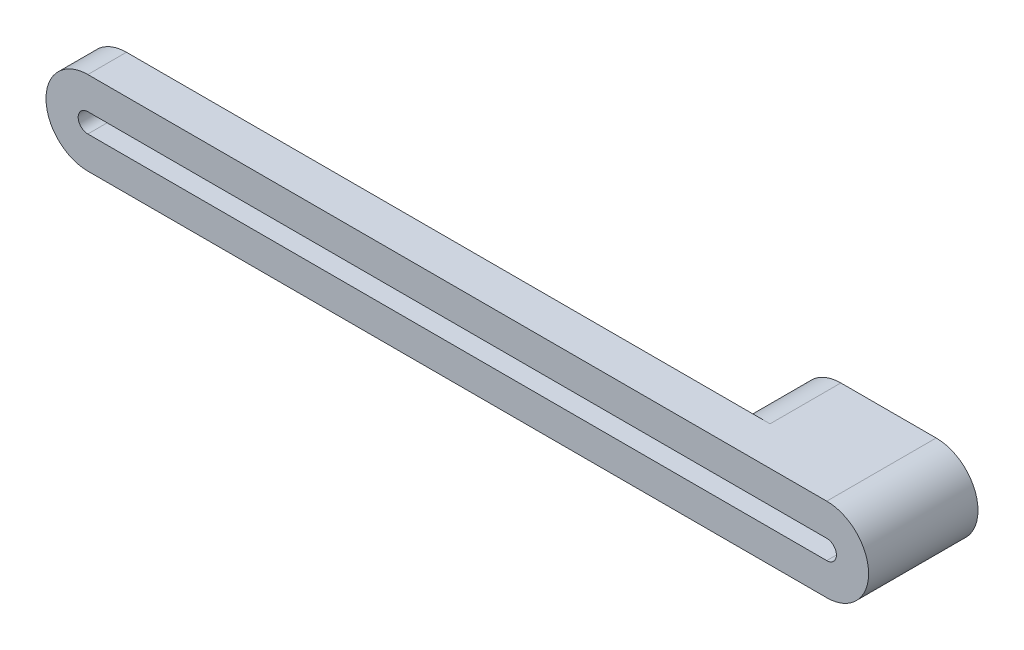
from build123d import *

# Parameters (mm, degrees)
BOSS_EXTRUDE1_DEPTH = 11
BOSS_EXTRUDE2_DEPTH = 6


with BuildPart() as part:
    # Sketch1 → Boss-Extrude1 (new body)
    with BuildSketch(Plane.XY):
        with BuildLine():
            Line((-68.865823893, 22.791817364), (-83.675684171, 22.791817364))
            ThreePointArc((-83.675684171, 22.791817364), (-90.175684171, 16.291817364), (-83.675684171, 9.791817364))
            Line((-83.675684171, 9.791817364), (-68.865823893, 9.791817364))
            ThreePointArc((-68.865823893, 9.791817364), (-62.365823893, 16.291817364), (-68.865823893, 22.791817364))
        make_face()
        with BuildLine():
            Line((-68.865823893, 17.791817364), (-83.675684171, 17.791817364))
            ThreePointArc((-83.675684171, 17.791817364), (-85.175684171, 16.291817364), (-83.675684171, 14.791817364))
            Line((-83.675684171, 14.791817364), (-68.865823893, 14.791817364))
            ThreePointArc((-68.865823893, 14.791817364), (-67.365823893, 16.291817364), (-68.865823893, 17.791817364))
        make_face(mode=Mode.SUBTRACT)
    extrude(amount=BOSS_EXTRUDE1_DEPTH)

    # Sketch2 → Boss-Extrude2 (add)
    with BuildSketch(Plane.XY.offset(11)):
        with BuildLine():
            Line((-183.675684171, 22.791817364), (-83.675684171, 22.791817364))
            Line((-83.675684171, 22.791817364), (-68.865823893, 22.791817364))
            ThreePointArc((-68.865823893, 22.791817364), (-62.365823893, 16.291817364), (-68.865823893, 9.791817364))
            Line((-68.865823893, 9.791817364), (-83.675684171, 9.791817364))
            Line((-83.675684171, 9.791817364), (-183.675684171, 9.791817364))
            ThreePointArc((-183.675684171, 9.791817364), (-190.175684171, 16.291817364), (-183.675684171, 22.791817364))
        make_face()
        with BuildLine():
            Line((-183.675684171, 17.791817364), (-83.675684171, 17.791817364))
            Line((-83.675684171, 17.791817364), (-68.865823893, 17.791817364))
            ThreePointArc((-68.865823893, 17.791817364), (-67.365823893, 16.291817364), (-68.865823893, 14.791817364))
            Line((-68.865823893, 14.791817364), (-83.675684171, 14.791817364))
            Line((-83.675684171, 14.791817364), (-183.675684171, 14.791817364))
            ThreePointArc((-183.675684171, 14.791817364), (-185.175684171, 16.291817364), (-183.675684171, 17.791817364))
        make_face(mode=Mode.SUBTRACT)
    extrude(amount=BOSS_EXTRUDE2_DEPTH)


solid = part.part
